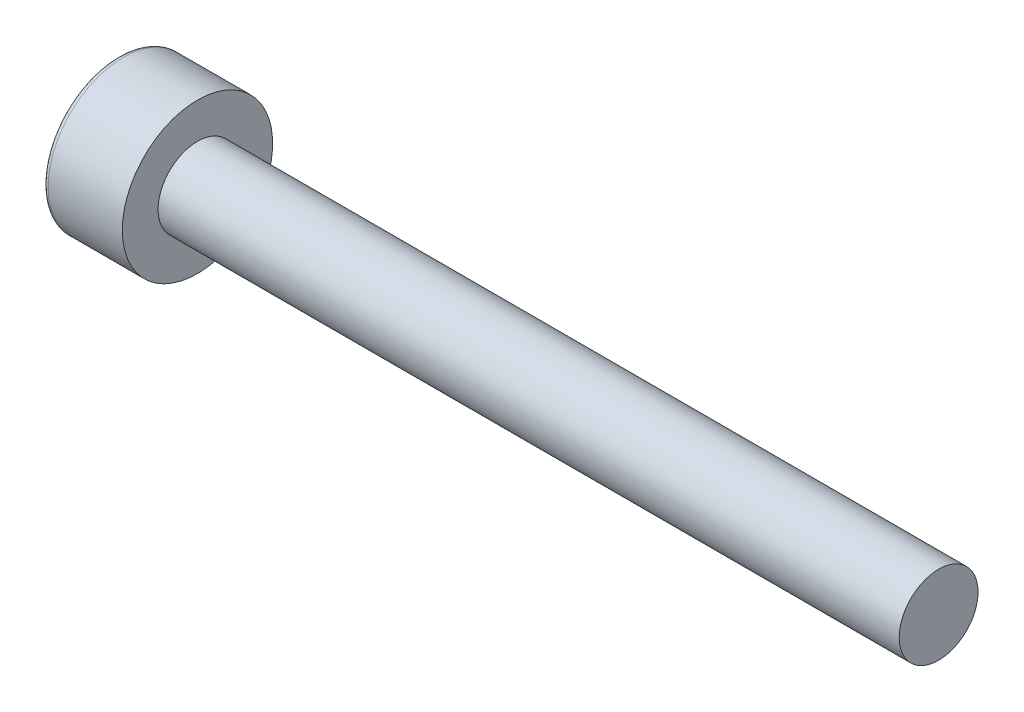
from build123d import *

# Parameters (mm, degrees)
CUT_EXTRUDE_1_DEPTH = 1.3
FILLET_1_R          = 0.2


with BuildPart() as part:
    # 草图1 → 旋转1 (revolve)
    with BuildSketch(Plane.XY):
        Polygon((0, 0), (0, 2.84), (3, 2.84), (3, 1.49), (31, 1.49), (31, 0), align=None)
    revolve(axis=Axis((0, 0, 0), (1, 0, 0)))

    # 草图2 → 切除-拉伸1 (cut)
    with BuildSketch(Plane.ZY):
        Polygon((-1.443375673, 0), (-0.721687836, -1.25), (0.721687836, -1.25), (1.443375673, 0), (0.721687836, 1.25), (-0.721687836, 1.25), align=None)
    extrude(amount=-CUT_EXTRUDE_1_DEPTH, mode=Mode.SUBTRACT)

    # 圆角1
    fillet_1_edges = [part.edges().sort_by_distance(p)[0] for p in [
        (0, -2.84, 0),
    ]]
    fillet(fillet_1_edges, radius=FILLET_1_R)


solid = part.part
